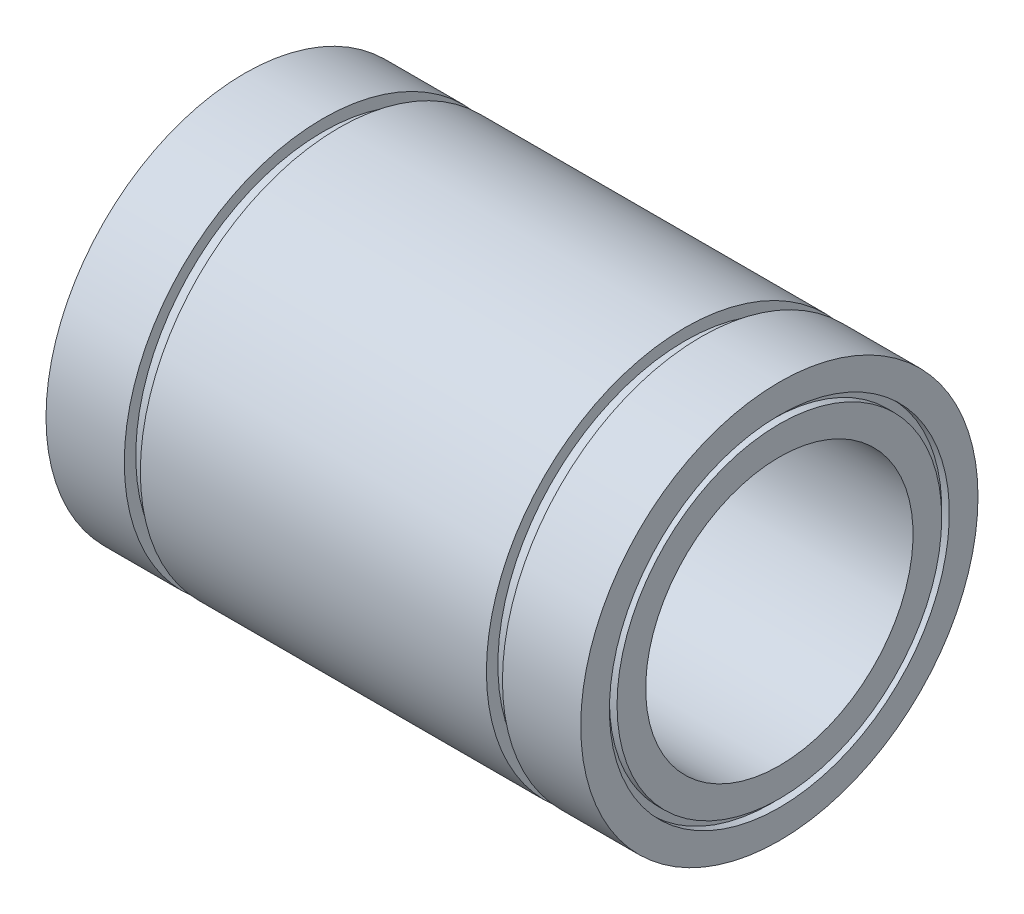
from build123d import *


with BuildPart() as part:
    # Esboço1 → Revolução1 (revolve)
    with BuildSketch(Plane.XY):
        Polygon((-35, 26), (-24.75, 26), (-24.75, 24.5), (-22.65, 24.5), (-22.65, 26), (22.65, 26), (22.65, 24.5), (24.75, 24.5), (24.75, 26), (35, 26), (35, 22.25), (34, 22.25), (34, 21.25), (35, 21.25), (35, 17.5), (-35, 17.5), (-35, 21.25), (-34, 21.25), (-34, 22.25), (-35, 22.25), align=None)
    revolve(axis=Axis((0, 0, 0), (-1, 0, 0)))


solid = part.part
